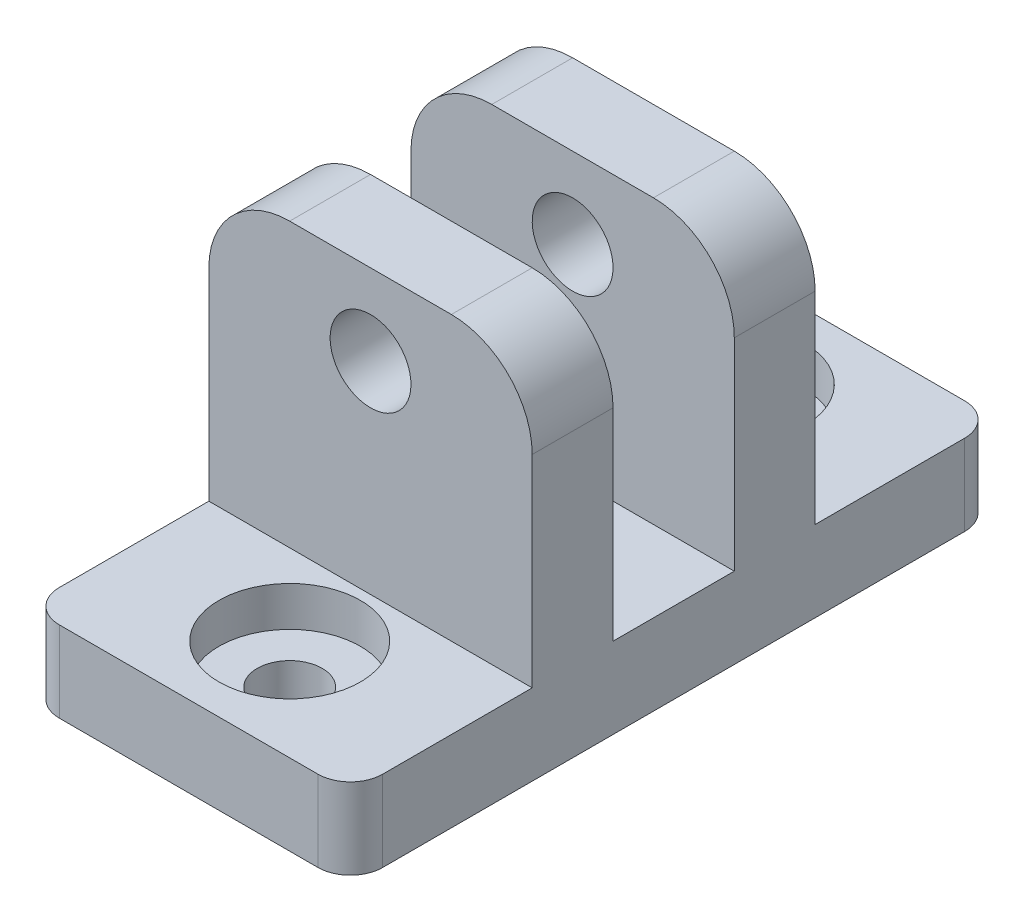
from build123d import *

# Parameters (mm, degrees)
SKETCH2_W                                           = 25.4
SKETCH2_H                                           = 50.8
BOSS_EXTRUDE2_DEPTH                                 = 28.575
SKETCH3_W                                           = 14.2875
SKETCH3_H                                           = 22.225
SKETCH3_W_2                                         = 9.525
CUT_EXTRUDE1_DEPTH                                  = 26.4
CBORE_FOR_10_BINDING_HEAD_MACHINE_SCREW_D           = 5.1054
CBORE_FOR_10_BINDING_HEAD_MACHINE_SCREW_DEPTH       = 6.35
CBORE_FOR_10_BINDING_HEAD_MACHINE_SCREW_CBORE_D     = 11.1125
CBORE_FOR_10_BINDING_HEAD_MACHINE_SCREW_CBORE_DEPTH = 3.1242
CBORE_FOR_10_BINDING_HEAD_MACHINE_SCREW_TIP         = 1.533816902
SKETCH8_R                                           = 3.175
CUT_EXTRUDE3_DEPTH                                  = 37.5125
FILLET1_R                                           = 6.35
FILLET2_R                                           = 2.54


with BuildPart() as part:
    # Sketch2 → Boss-Extrude2 (new body)
    with BuildSketch(Plane(origin=(0, 0, 0), x_dir=(1, 0, 0), z_dir=(0, 1, 0))):
        Rectangle(SKETCH2_W, SKETCH2_H)
    extrude(amount=BOSS_EXTRUDE2_DEPTH)

    # Sketch3 → Cut-Extrude1 (cut, through all)
    with BuildSketch(Plane(origin=(12.7, 0, 0), x_dir=(0, 0, -1), z_dir=(1, 0, 0))):
        with Locations((-18.25625, 17.4625)):
            Rectangle(SKETCH3_W, SKETCH3_H)
        with Locations((18.25625, 17.4625)):
            Rectangle(SKETCH3_W, SKETCH3_H)
        with Locations((0, 17.4625)):
            Rectangle(SKETCH3_W_2, SKETCH3_H)
    extrude(amount=-CUT_EXTRUDE1_DEPTH, mode=Mode.SUBTRACT)

    # CBORE for #10 Binding Head Machine Screw1
    with Locations(Plane(origin=(0, 6.35, 0), x_dir=(1, 0, 0), z_dir=(0, 1, 0))):
        with Locations((0, -17.4625), (0, 17.4625)):
            CounterBoreHole(CBORE_FOR_10_BINDING_HEAD_MACHINE_SCREW_D / 2, CBORE_FOR_10_BINDING_HEAD_MACHINE_SCREW_CBORE_D / 2, CBORE_FOR_10_BINDING_HEAD_MACHINE_SCREW_CBORE_DEPTH, depth=CBORE_FOR_10_BINDING_HEAD_MACHINE_SCREW_DEPTH)
            with Locations((0, 0, -(CBORE_FOR_10_BINDING_HEAD_MACHINE_SCREW_DEPTH + CBORE_FOR_10_BINDING_HEAD_MACHINE_SCREW_TIP / 2))):  # 118° drill point
                Cone(0, CBORE_FOR_10_BINDING_HEAD_MACHINE_SCREW_D / 2, CBORE_FOR_10_BINDING_HEAD_MACHINE_SCREW_TIP, mode=Mode.SUBTRACT)

    # Sketch8 → Cut-Extrude3 (cut, through all)
    with BuildSketch(Plane(origin=(0, 0, -11.1125), x_dir=(-1, 0, 0), z_dir=(0, 0, -1))):
        with Locations((0, 22.225)):
            Circle(SKETCH8_R)
    extrude(amount=-CUT_EXTRUDE3_DEPTH, mode=Mode.SUBTRACT)

    # Fillet1
    fillet1_edges = [part.edges().sort_by_distance(p)[0] for p in [
        (12.7, 28.575, 7.9375),
        (-12.7, 28.575, -7.9375),
        (-12.7, 28.575, 7.9375),
        (12.7, 28.575, -7.9375),
    ]]
    fillet(fillet1_edges, radius=FILLET1_R)

    # Fillet2
    fillet2_edges = [part.edges().sort_by_distance(p)[0] for p in [
        (12.7, 3.175, 25.4),
        (-12.7, 3.175, 25.4),
        (-12.7, 3.175, -25.4),
        (12.7, 3.175, -25.4),
    ]]
    fillet(fillet2_edges, radius=FILLET2_R)


solid = part.part
